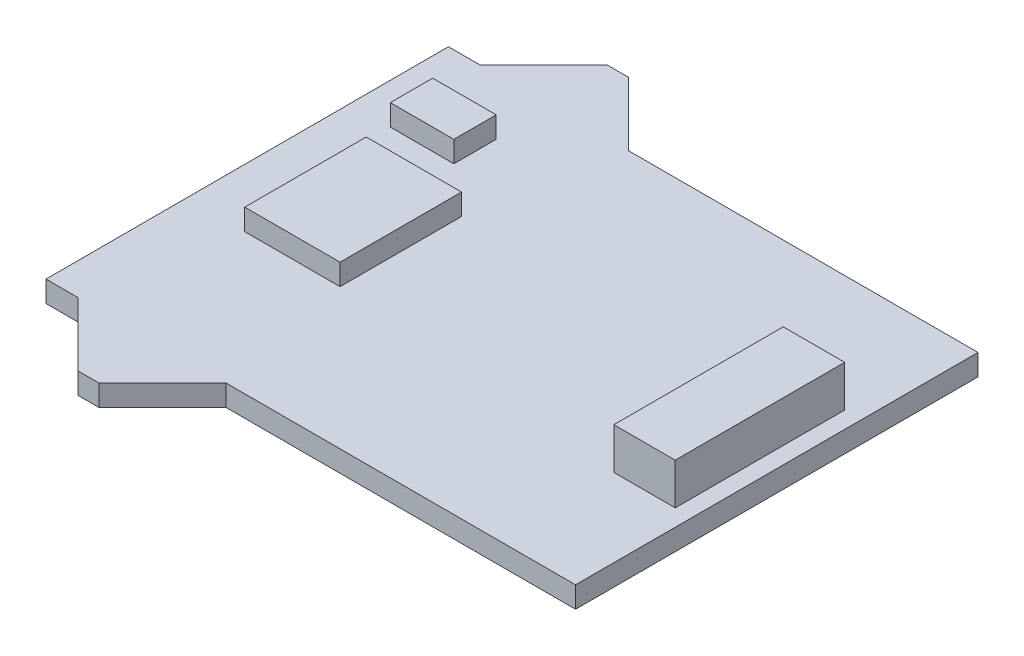
from build123d import *

# Parameters (mm, degrees)
BOSS_EXTRUDE1_DEPTH = 1.000000032
SKETCH2_W           = 4.49999989
SKETCH2_H           = 5.735208424
SKETCH2_W_2         = 3
SKETCH2_H_2         = 2
BOSS_EXTRUDE2_DEPTH = 1
SKETCH3_W           = 2.900000042
SKETCH3_H           = 8.000000002
BOSS_EXTRUDE3_DEPTH = 1.94999991


with BuildPart() as part:
    # Sketch1 → Boss-Extrude1 (new body)
    with BuildSketch(Plane(origin=(0, 0, 0), x_dir=(1, 0, 0), z_dir=(0, 1, 0))):
        Polygon((-3.499999985, 9.50000005), (-0.499999889, 12.500000146), (0.499999889, 12.500000146), (3.499999985, 9.50000005), (4.999999906, 9.50000005), (20.000000132, 9.50000005), (20.000000132, -9.50000005), (4.999999906, -9.50000005), (3.499999985, -9.50000005), (0.499999889, -12.500000146), (-0.499999889, -12.500000146), (-3.499999985, -9.50000005), (-4.999999906, -9.50000005), (-4.999999906, 9.50000005), align=None)
    extrude(amount=-BOSS_EXTRUDE1_DEPTH)

    # Sketch2 → Boss-Extrude2 (add)
    with BuildSketch(Plane(origin=(0, 0, 0), x_dir=(1, 0, 0), z_dir=(0, 1, 0))):
        Rectangle(SKETCH2_W, SKETCH2_H)
        with Locations((-1.5875, 5.842)):
            Rectangle(SKETCH2_W_2, SKETCH2_H_2)
    extrude(amount=BOSS_EXTRUDE2_DEPTH)

    # Sketch3 → Boss-Extrude3 (add)
    with BuildSketch(Plane(origin=(0, 0, 0), x_dir=(1, 0, 0), z_dir=(0, 1, 0))):
        with Locations((17.756250111, 0)):
            Rectangle(SKETCH3_W, SKETCH3_H)
    extrude(amount=BOSS_EXTRUDE3_DEPTH)


solid = part.part
